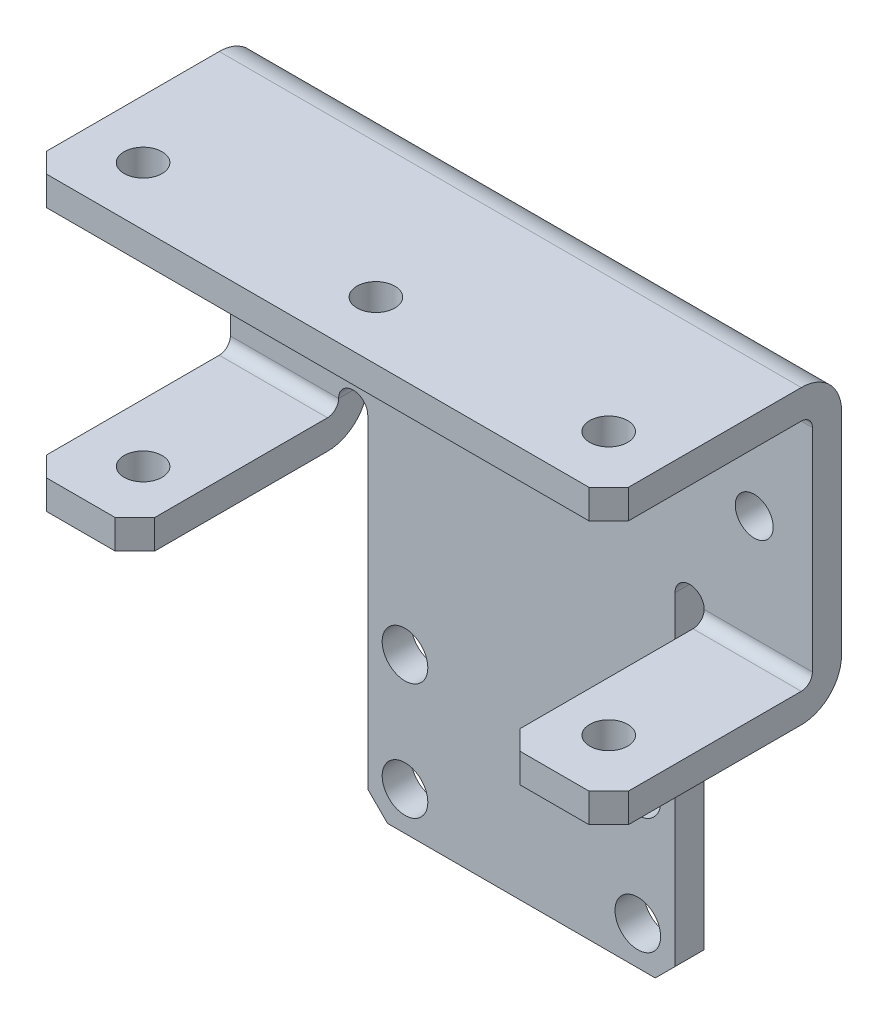
from build123d import *

# Parameters (mm, degrees)
BOSS_EXTRUDE1_DEPTH        = 3.175
SKETCH2_W                  = 63.5
SKETCH2_H                  = 3.175
BOSS_EXTRUDE2_DEPTH        = 22.225
SKETCH3_W                  = 11.811
SKETCH3_H                  = 3.175
BOSS_EXTRUDE3_DEPTH        = 22.225
SKETCH4_W                  = 11.811
SKETCH4_H                  = 3.175
BOSS_EXTRUDE4_DEPTH        = 22.225
HOLE1_D                    = 4.9784
HOLE1_DEPTH                = 3.175
M3_5_CLEARANCE_HOLE1_D     = 4.1402
M3_5_CLEARANCE_HOLE1_DEPTH = 3.175
M3_5_CLEARANCE_HOLE2_D     = 4.1402
M3_5_CLEARANCE_HOLE2_DEPTH = 3.175
M3_5_CLEARANCE_HOLE3_D     = 4.1402
M3_5_CLEARANCE_HOLE3_DEPTH = 31.877
CHAMFER1_SIZE              = 2.159
FILLET1_R                  = 1.2192
FILLET2_R                  = 4.3942


with BuildPart() as part:
    # Sketch1 → Boss-Extrude1 (new body)
    with BuildSketch(Plane(origin=(0, 0, 0), x_dir=(-1, 0, 0), z_dir=(0, 0, -1))):
        with BuildLine():
            Line((-16.764, -49.0347), (16.764, -49.0347))
            Line((16.764, -49.0347), (16.764, -11.5443))
            ThreePointArc((16.764, -11.5443), (18.3515, -9.9568), (19.939, -11.5443))
            Line((19.939, -11.5443), (19.939, -15.9385))
            Line((19.939, -15.9385), (31.75, -15.9385))
            Line((31.75, -15.9385), (31.75, 15.9385))
            Line((31.75, 15.9385), (-31.75, 15.9385))
            Line((-31.75, 15.9385), (-31.75, -15.9385))
            Line((-31.75, -15.9385), (-19.939, -15.9385))
            Line((-19.939, -15.9385), (-19.939, -11.5443))
            ThreePointArc((-19.939, -11.5443), (-18.3515, -9.9568), (-16.764, -11.5443))
            Line((-16.764, -11.5443), (-16.764, -49.0347))
        make_face()
    extrude(amount=-BOSS_EXTRUDE1_DEPTH)

    # Sketch2 → Boss-Extrude2 (add)
    with BuildSketch(Plane.XY.offset(3.175)):
        with Locations((0, 14.351)):
            Rectangle(SKETCH2_W, SKETCH2_H)
    extrude(amount=BOSS_EXTRUDE2_DEPTH)

    # Sketch3 → Boss-Extrude3 (add)
    with BuildSketch(Plane.XY.offset(3.175)):
        with Locations((25.8445, -14.351)):
            Rectangle(SKETCH3_W, SKETCH3_H)
    extrude(amount=BOSS_EXTRUDE3_DEPTH)

    # Sketch4 → Boss-Extrude4 (add)
    with BuildSketch(Plane.XY.offset(3.175)):
        with Locations((-25.8445, -14.351)):
            Rectangle(SKETCH4_W, SKETCH4_H)
    extrude(amount=BOSS_EXTRUDE4_DEPTH)

    # Hole1
    with Locations(Plane.XY.offset(3.175)):
        with Locations((12.7, -44.831), (-12.7, -44.831), (-12.7, -32.131), (12.7, -32.131), (-12.7, 0), (12.7, 0)):
            Hole(HOLE1_D / 2, depth=HOLE1_DEPTH)

    # M3.5 Clearance Hole1
    with Locations(Plane.XY.offset(3.175)):
        with Locations((-25.4, 0), (25.4, 0)):
            Hole(M3_5_CLEARANCE_HOLE1_D / 2, depth=M3_5_CLEARANCE_HOLE1_DEPTH)

    # M3.5 Clearance Hole2
    with Locations(Plane(origin=(0, 15.9385, 0), x_dir=(1, 0, 0), z_dir=(0, 1, 0))):
        with Locations((25.4, -19.05), (0, -19.05), (-25.4, -19.05)):
            Hole(M3_5_CLEARANCE_HOLE2_D / 2, depth=M3_5_CLEARANCE_HOLE2_DEPTH)

    # M3.5 Clearance Hole3
    with Locations(Plane(origin=(0, -15.9385, 0), x_dir=(-1, 0, 0), z_dir=(0, -1, 0))):
        with Locations((-25.4, -19.05), (25.4, -19.05)):
            Hole(M3_5_CLEARANCE_HOLE3_D / 2, depth=M3_5_CLEARANCE_HOLE3_DEPTH)

    # Chamfer1
    chamfer1_edges = [part.edges().sort_by_distance(p)[0] for p in [
        (-19.939, -14.351, 25.4),
        (31.75, 14.351, 25.4),
        (31.75, -14.351, 25.4),
        (16.764, -49.0347, 1.5875),
        (-31.75, 14.351, 25.4),
        (-31.75, -14.351, 25.4),
        (19.939, -14.351, 25.4),
        (-16.764, -49.0347, 1.5875),
    ]]
    chamfer(chamfer1_edges, length=CHAMFER1_SIZE)

    # Fillet1
    fillet1_edges = [part.edges().sort_by_distance(p)[0] for p in [
        (25.8445, -12.7635, 3.175),
        (-25.8445, -12.7635, 3.175),
        (0, 12.7635, 3.175),
    ]]
    fillet(fillet1_edges, radius=FILLET1_R)

    # Fillet2
    fillet2_edges = [part.edges().sort_by_distance(p)[0] for p in [
        (25.8445, -15.9385, 0),
        (-25.8445, -15.9385, 0),
        (0, 15.9385, 0),
    ]]
    fillet(fillet2_edges, radius=FILLET2_R)


solid = part.part
